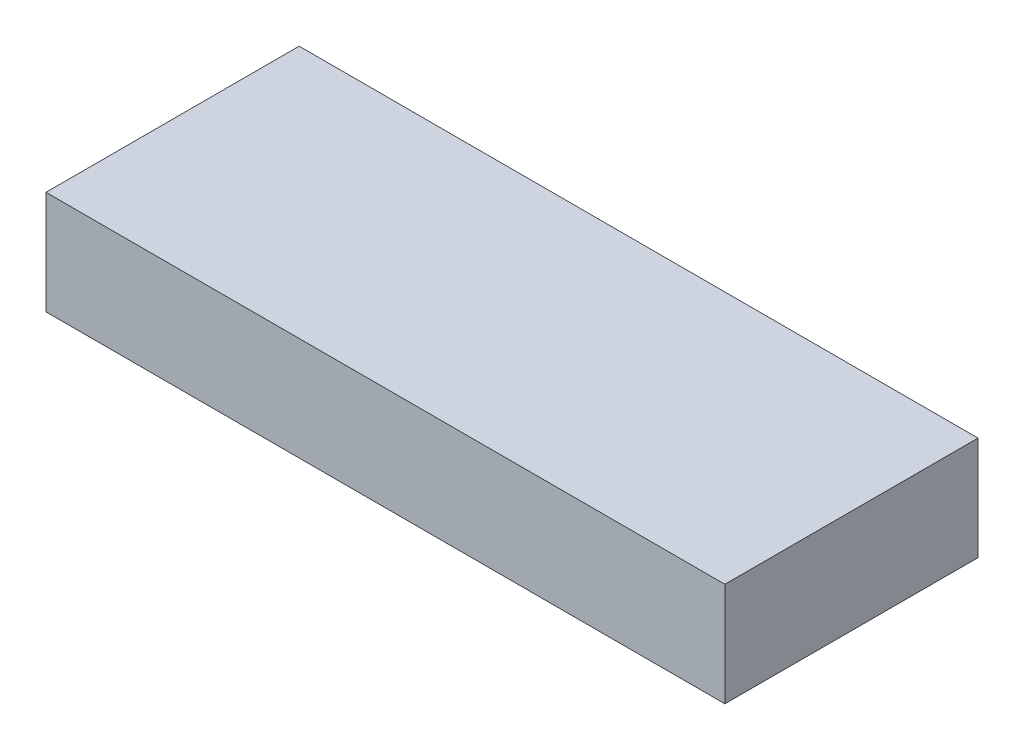
from build123d import *

# Parameters (mm, degrees)
SKETCH1_W      = 118
SKETCH1_H      = 44
EXTRUDE1_DEPTH = 9


with BuildPart() as part:
    # Sketch1 → Extrude1 (new body, symmetric)
    with BuildSketch(Plane(origin=(0, 0, 0), x_dir=(1, 0, 0), z_dir=(0, 1, 0))):
        Rectangle(SKETCH1_W, SKETCH1_H)
    extrude(amount=EXTRUDE1_DEPTH, both=True)


solid = part.part
